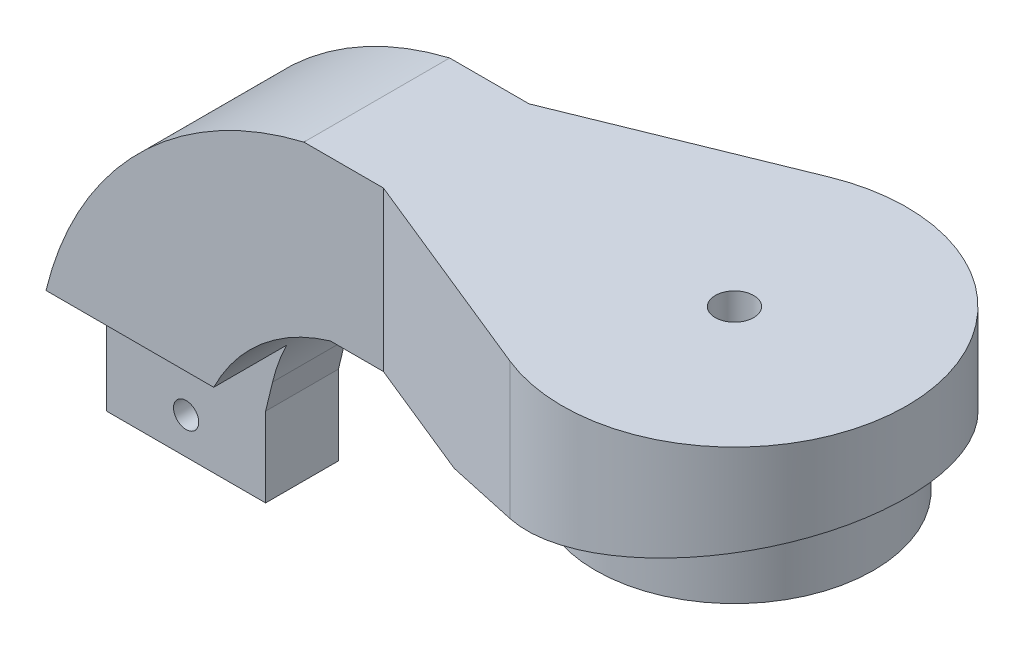
from build123d import *

# Parameters (mm, degrees)
BOSS_EXTRUDE1_DEPTH = 24
CUT_EXTRUDE1_DEPTH  = 29.5
SKETCH3_R           = 21
BOSS_EXTRUDE2_DEPTH = 24
CUT_EXTRUDE2_DEPTH  = 4
BOSS_EXTRUDE3_DEPTH = 11
SKETCH6_W           = 89
SKETCH6_H           = 21.5
SKETCH7_W           = 48
SKETCH7_H           = 22
BOSS_EXTRUDE4_DEPTH = 3.027047
SKETCH8_R           = 18.5
CUT_EXTRUDE3_DEPTH  = 83
CUT_EXTRUDE4_REACH  = 91
SKETCH9_R           = 1.6
SKETCH9_R_2         = 6.1
CUT_EXTRUDE5_REACH  = 125.5
SKETCH10_R          = 2.9
CUT_EXTRUDE6_REACH  = 136
SKETCH13_R          = 1.9
CUT_EXTRUDE7_DEPTH  = 27


with BuildPart() as part:
    # Sketch1 → Boss-Extrude1 (new body)
    with BuildSketch(Plane(origin=(0, 0, 0), x_dir=(1, 0, 0), z_dir=(0, 1, 0))):
        with BuildLine():
            Line((-42, 0), (-42, 11))
            Line((-42, 11), (-9.786517927, 24.087840644))
            ThreePointArc((-9.786517927, 24.087840644), (26, 0), (-9.786517927, -24.087840644))
            Line((-9.786517927, -24.087840644), (-42, -11))
            Line((-42, -11), (-42, 0))
        make_face()
    extrude(amount=BOSS_EXTRUDE1_DEPTH)

    # Sketch2 → Cut-Extrude1 (cut, symmetric)
    with BuildSketch(Plane.XY):
        Polygon((-24, 0), (26, 12), (26, 0), align=None)
    extrude(amount=CUT_EXTRUDE1_DEPTH, both=True, mode=Mode.SUBTRACT)

    # Sketch3 → Boss-Extrude2 (add)
    with BuildSketch(Plane(origin=(0, 24, 0), x_dir=(1, 0, 0), z_dir=(0, 1, 0))):
        Circle(SKETCH3_R)
    extrude(amount=-BOSS_EXTRUDE2_DEPTH)

    # Sketch4 → Cut-Extrude2 (cut)
    with BuildSketch(Plane.XZ):
        Polygon((2.829016319, 4.9), (-2.829016319, 4.9), (-5.658032638, 0), (-2.829016319, -4.9), (2.829016319, -4.9), (5.658032638, 0), align=None)
    extrude(amount=-CUT_EXTRUDE2_DEPTH, mode=Mode.SUBTRACT)

    # Sketch5 → Boss-Extrude3 (add, symmetric)
    with BuildSketch(Plane.XY):
        with BuildLine():
            ThreePointArc((-54, 24), (-78.945219608, 10.049710337), (-92.941825352, -14.869551102))
            Line((-92.941825352, -14.869551102), (-94.786517927, -22.5))
            Line((-94.786517927, -22.5), (-94.786517927, -37.075307894))
            Line((-94.786517927, -37.075307894), (-93.178015205, -46.5))
            Line((-93.178015205, -46.5), (-90, -56.5))
            Line((-90, -56.5), (-42, -56.5))
            Line((-42, -56.5), (-63.178015205, -46.5))
            Line((-63.178015205, -46.5), (-70.786517927, -37.075307894))
            Line((-70.786517927, -37.075307894), (-70.786517927, -25.075307894))
            Line((-70.786517927, -25.075307894), (-69.738862808, -20.741751748))
            ThreePointArc((-69.738862808, -20.741751748), (-62.647337683, -7.727284744), (-50, 0))
            Line((-50, 0), (-42, 0))
            Line((-42, 0), (-42, 24))
            Line((-42, 24), (-54, 24))
        make_face()
    extrude(amount=BOSS_EXTRUDE3_DEPTH, both=True)



with BuildPart() as body_2:
    # Sketch6 → Revolve1 (revolve)
    with BuildSketch(Plane.XY):
        with Locations((-53.5, -88.75)):
            Rectangle(SKETCH6_W, SKETCH6_H)
    revolve(axis=Axis((-98, -78, 0), (1, 0, 0)))


with BuildPart() as part_1:
    add(part.part)

    add(body_2.part)  # Boss-Extrude4 merges body 2
    # Sketch7 → Boss-Extrude4 (add)
    with BuildSketch(Plane.XZ.offset(56.5)):
        with Locations((-66, 0)):
            Rectangle(SKETCH7_W, SKETCH7_H)
    extrude(amount=BOSS_EXTRUDE4_DEPTH)

    # Sketch8 → Cut-Extrude3 (cut)
    with BuildSketch(Plane.ZY.offset(98)):
        with Locations((0, -78)):
            Circle(SKETCH8_R)
    extrude(amount=-CUT_EXTRUDE3_DEPTH, mode=Mode.SUBTRACT)

    # Sketch9 → Cut-Extrude4 (cut, up to next)
    with BuildSketch(Plane(origin=(-9, 0, 0), x_dir=(0, 0, -1), z_dir=(1, 0, 0)), mode=Mode.PRIVATE) as cut_extrude4_sk1:
        with Locations((15.5, -78)):
            Circle(SKETCH9_R)
    cut_extrude4_tool1 = extrude(cut_extrude4_sk1.sketch, amount=-CUT_EXTRUDE4_REACH, mode=Mode.PRIVATE) & part_1.part
    add(cut_extrude4_tool1.solids().sort_by_distance((-9, -78, -15.5))[0], mode=Mode.SUBTRACT)
    # Sketch9 → Cut-Extrude4 (cut, up to next)
    with BuildSketch(Plane(origin=(-9, 0, 0), x_dir=(0, 0, -1), z_dir=(1, 0, 0)), mode=Mode.PRIVATE) as cut_extrude4_sk2:
        with Locations((7.75, -91.423393759)):
            Circle(SKETCH9_R)
    cut_extrude4_tool2 = extrude(cut_extrude4_sk2.sketch, amount=-CUT_EXTRUDE4_REACH, mode=Mode.PRIVATE) & part_1.part
    add(cut_extrude4_tool2.solids().sort_by_distance((-9, -91.423394, -7.75))[0], mode=Mode.SUBTRACT)
    # Sketch9 → Cut-Extrude4 (cut, up to next)
    with BuildSketch(Plane(origin=(-9, 0, 0), x_dir=(0, 0, -1), z_dir=(1, 0, 0)), mode=Mode.PRIVATE) as cut_extrude4_sk3:
        with Locations((-7.75, -91.423393759)):
            Circle(SKETCH9_R)
    cut_extrude4_tool3 = extrude(cut_extrude4_sk3.sketch, amount=-CUT_EXTRUDE4_REACH, mode=Mode.PRIVATE) & part_1.part
    add(cut_extrude4_tool3.solids().sort_by_distance((-9, -91.423394, 7.75))[0], mode=Mode.SUBTRACT)
    # Sketch9 → Cut-Extrude4 (cut, up to next)
    with BuildSketch(Plane(origin=(-9, 0, 0), x_dir=(0, 0, -1), z_dir=(1, 0, 0)), mode=Mode.PRIVATE) as cut_extrude4_sk4:
        with Locations((-15.5, -78)):
            Circle(SKETCH9_R)
    cut_extrude4_tool4 = extrude(cut_extrude4_sk4.sketch, amount=-CUT_EXTRUDE4_REACH, mode=Mode.PRIVATE) & part_1.part
    add(cut_extrude4_tool4.solids().sort_by_distance((-9, -78, 15.5))[0], mode=Mode.SUBTRACT)
    # Sketch9 → Cut-Extrude4 (cut, up to next)
    with BuildSketch(Plane(origin=(-9, 0, 0), x_dir=(0, 0, -1), z_dir=(1, 0, 0)), mode=Mode.PRIVATE) as cut_extrude4_sk5:
        with Locations((-7.75, -64.576606241)):
            Circle(SKETCH9_R)
    cut_extrude4_tool5 = extrude(cut_extrude4_sk5.sketch, amount=-CUT_EXTRUDE4_REACH, mode=Mode.PRIVATE) & part_1.part
    add(cut_extrude4_tool5.solids().sort_by_distance((-9, -64.576606, 7.75))[0], mode=Mode.SUBTRACT)
    # Sketch9 → Cut-Extrude4 (cut, up to next)
    with BuildSketch(Plane(origin=(-9, 0, 0), x_dir=(0, 0, -1), z_dir=(1, 0, 0)), mode=Mode.PRIVATE) as cut_extrude4_sk6:
        with Locations((7.75, -64.576606241)):
            Circle(SKETCH9_R)
    cut_extrude4_tool6 = extrude(cut_extrude4_sk6.sketch, amount=-CUT_EXTRUDE4_REACH, mode=Mode.PRIVATE) & part_1.part
    add(cut_extrude4_tool6.solids().sort_by_distance((-9, -64.576606, -7.75))[0], mode=Mode.SUBTRACT)
    # Sketch9 → Cut-Extrude4 (cut, up to next)
    with BuildSketch(Plane(origin=(-9, 0, 0), x_dir=(0, 0, -1), z_dir=(1, 0, 0)), mode=Mode.PRIVATE) as cut_extrude4_sk7:
        with Locations((0, -85)):
            Circle(SKETCH9_R_2)
    cut_extrude4_tool7 = extrude(cut_extrude4_sk7.sketch, amount=-CUT_EXTRUDE4_REACH, mode=Mode.PRIVATE) & part_1.part
    add(cut_extrude4_tool7.solids().sort_by_distance((-9, -85, 0))[0], mode=Mode.SUBTRACT)

    # Sketch10 → Cut-Extrude5 (cut, up to next)
    with BuildSketch(Plane(origin=(0, 24, 0), x_dir=(1, 0, 0), z_dir=(0, 1, 0)), mode=Mode.PRIVATE) as cut_extrude5_sk1:
        Circle(SKETCH10_R)
    cut_extrude5_tool1 = extrude(cut_extrude5_sk1.sketch, amount=-CUT_EXTRUDE5_REACH, mode=Mode.PRIVATE) & part_1.part
    add(cut_extrude5_tool1.solids().sort_by_distance((0, 24, 0))[0], mode=Mode.SUBTRACT)

    # Sketch12 → Cut-Extrude6 (cut, up to next)
    with BuildSketch(Plane.ZY.offset(108), mode=Mode.PRIVATE) as cut_extrude6_sk1:
        Polygon((0, -14.869551102), (0, -37.075307894), (-35.009935155, -37.075307894), (-35.009935155, -113.334550455), (34.515095082, -113.334550455), (34.515095082, -14.869551102), align=None)
    cut_extrude6_tool1 = extrude(cut_extrude6_sk1.sketch, amount=-CUT_EXTRUDE6_REACH, mode=Mode.PRIVATE) & part_1.part
    add(cut_extrude6_tool1.solids().sort_by_distance((-108, -68.986865, 1.963457))[0], mode=Mode.SUBTRACT)

    # Sketch13 → Cut-Extrude7 (cut, through all)
    with BuildSketch(Plane.XY):
        with Locations((-81.960177429, -20.369551102)):
            Circle(SKETCH13_R)
        with Locations((-82.786517927, -31.575307894)):
            Circle(SKETCH13_R)
    extrude(amount=-CUT_EXTRUDE7_DEPTH, mode=Mode.SUBTRACT)


solid = part_1.part
